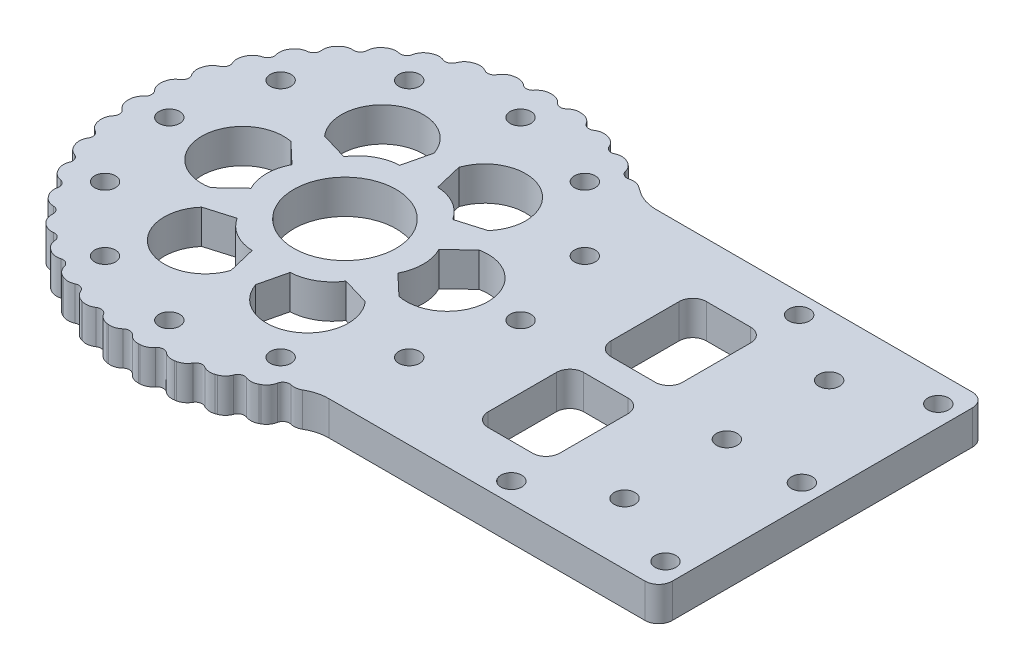
from build123d import *

# Parameters (mm, degrees)
EXTRUDE_1_DEPTH          = 5
FILLET_2_R               = 40
SKETCH_5_R               = 22.5
CUT_EXTRUDE_3_DEPTH      = 6
SKETCH_6_R               = 1.525
CUT_EXTRUDE_4_DEPTH      = 6
SKETCH_8_R               = 18.5
CUT_EXTRUDE_6_DEPTH      = 6
SKETCH_9_R               = 1.275
CUT_EXTRUDE_7_DEPTH      = 6
SKETCH_11_R              = 42.5
EXTRUDE_2_DEPTH          = 5
FILLET_4_R               = 20
SKETCH_13_R              = 31
CUT_EXTRUDE_10_DEPTH     = 5
SKETCH_14_R              = 37.5
EXTRUDE_3_DEPTH          = 5
SKETCH_15_R              = 28.5
CUT_EXTRUDE_11_DEPTH     = 5
SKETCH_16_R              = 2.025
CUT_EXTRUDE_12_DEPTH     = 5
FILLET_5_R               = 20
SKETCH_17_R              = 31
EXTRUDE_4_DEPTH          = 5
CUT_EXTRUDE_13_DEPTH     = 10
PATTERN_CIRCULAR_1_COUNT = 6
SKETCH_19_R              = 7.5
CUT_EXTRUDE_14_DEPTH     = 10
SKETCH_20_W              = 205.824905301
SKETCH_20_H              = 126.942256866
CUT_EXTRUDE_15_DEPTH     = 6.0000001
CUT_EXTRUDE_16_DEPTH     = 6.0000001
SKETCH_23_R              = 1.525
CUT_EXTRUDE_17_DEPTH     = 6
SKETCH_26_R              = 1.525
CUT_EXTRUDE_18_DEPTH     = 6
SKETCH_27_W              = 10.5
SKETCH_27_H              = 14
CUT_EXTRUDE_19_DEPTH     = 6
FILLET_6_R               = 2
FILLET_8_R               = 2
FILLET_10_R              = 2
FILLET_11_R              = 6
SKETCH_28_R              = 1
CUT_EXTRUDE_20_DEPTH     = 6
PATTERN_CIRCULAR_2_COUNT = 40
FILLET_12_R              = 2
SKETCH_29_R              = 1.525
CUT_EXTRUDE_21_DEPTH     = 6.0000001
SKETCH_30_R              = 1.525
CUT_EXTRUDE_22_DEPTH     = 6.0000001


with BuildPart() as part:
    # 草图1 → 凸台-拉伸1 (new body)
    with BuildSketch(Plane(origin=(0, 0, 0), x_dir=(1, 0, 0), z_dir=(0, 1, 0))):
        with BuildLine():
            Line((105, 24), (-76.839744319, 24))
            ThreePointArc((-76.839744319, 24), (-142, 0), (-76.839744319, -24))
            Line((-76.839744319, -24), (105, -24))
            ThreePointArc((105, -24), (129, 0), (105, 24))
        make_face()
    extrude(amount=EXTRUDE_1_DEPTH)

    # 圆角2
    fillet_2_edges = [part.edges().sort_by_distance(p)[0] for p in [
        (-76.839744319, 2.5, -24),
        (-76.839744319, 2.5, 24),
    ]]
    fillet(fillet_2_edges, radius=FILLET_2_R)

    # 草图5 → 切除-拉伸3 (cut, through all)
    with BuildSketch(Plane(origin=(0, 5, 0), x_dir=(1, 0, 0), z_dir=(0, 1, 0))):
        with Locations((-105, 0)):
            Circle(SKETCH_5_R)
    extrude(amount=-CUT_EXTRUDE_3_DEPTH, mode=Mode.SUBTRACT)

    # 草图6 → 切除-拉伸4 (cut, through all)
    with BuildSketch(Plane(origin=(0, 5, 0), x_dir=(1, 0, 0), z_dir=(0, 1, 0))):
        with Locations((-135, 0)):
            Circle(SKETCH_6_R)
        with Locations((-120, 25.980762114)):
            Circle(SKETCH_6_R)
        with Locations((-90, 25.980762114)):
            Circle(SKETCH_6_R)
        with Locations((-75, 0)):
            Circle(SKETCH_6_R)
        with Locations((-90, -25.980762114)):
            Circle(SKETCH_6_R)
        with Locations((-120, -25.980762114)):
            Circle(SKETCH_6_R)
    extrude(amount=-CUT_EXTRUDE_4_DEPTH, mode=Mode.SUBTRACT)

    # 草图8 → 切除-拉伸6 (cut, through all)
    with BuildSketch(Plane(origin=(0, 5, 0), x_dir=(1, 0, 0), z_dir=(0, 1, 0))):
        with Locations((105, 0)):
            Circle(SKETCH_8_R)
    extrude(amount=-CUT_EXTRUDE_6_DEPTH, mode=Mode.SUBTRACT)

    # 草图9 → 切除-拉伸7 (cut, through all)
    with BuildSketch(Plane(origin=(0, 5, 0), x_dir=(1, 0, 0), z_dir=(0, 1, 0))):
        with Locations((130, 0)):
            Circle(SKETCH_9_R)
        with Locations((117.5, -21.650635095)):
            Circle(SKETCH_9_R)
        with Locations((92.5, -21.650635095)):
            Circle(SKETCH_9_R)
        with Locations((80, 0)):
            Circle(SKETCH_9_R)
        with Locations((92.5, 21.650635095)):
            Circle(SKETCH_9_R)
        with Locations((117.5, 21.650635095)):
            Circle(SKETCH_9_R)
    extrude(amount=-CUT_EXTRUDE_7_DEPTH, mode=Mode.SUBTRACT)

    # 草图11 → 凸台-拉伸2 (add)
    with BuildSketch(Plane(origin=(0, 5, 0), x_dir=(1, 0, 0), z_dir=(0, 1, 0))):
        with Locations((-105.000156976, -0.000208065)):
            Circle(SKETCH_11_R)
    extrude(amount=-EXTRUDE_2_DEPTH)

    # 圆角4
    fillet_4_edges = [part.edges().sort_by_distance(p)[0] for p in [
        (-70.546104762, 2.5, 24.883300437),
        (-70.546460155, 2.5, -24.88337639),
    ]]
    fillet(fillet_4_edges, radius=FILLET_4_R)

    # 草图13 → 切除-拉伸10 (cut)
    with BuildSketch(Plane(origin=(0, 5, 0), x_dir=(1, 0, 0), z_dir=(0, 1, 0))):
        with Locations((-105.000156976, -0.000208065)):
            Circle(SKETCH_13_R)
    extrude(amount=-CUT_EXTRUDE_10_DEPTH, mode=Mode.SUBTRACT)

    # 草图14 → 凸台-拉伸3 (add)
    with BuildSketch(Plane(origin=(0, 5, 0), x_dir=(1, 0, 0), z_dir=(0, 1, 0))):
        with Locations((104.999843024, -0.000208065)):
            Circle(SKETCH_14_R)
    extrude(amount=-EXTRUDE_3_DEPTH)

    # 草图15 → 切除-拉伸11 (cut)
    with BuildSketch(Plane(origin=(0, 5, 0), x_dir=(1, 0, 0), z_dir=(0, 1, 0))):
        with Locations((104.999843024, -0.000208065)):
            Circle(SKETCH_15_R)
    extrude(amount=-CUT_EXTRUDE_11_DEPTH, mode=Mode.SUBTRACT)

    # 草图16 → 切除-拉伸12 (cut)
    with BuildSketch(Plane(origin=(0, 5, 0), x_dir=(1, 0, 0), z_dir=(0, 1, 0))):
        with Locations((137.999843024, -0.000208065)):
            Circle(SKETCH_16_R)
        with Locations((121.499843024, -28.57904639)):
            Circle(SKETCH_16_R)
        with Locations((88.499843024, -28.57904639)):
            Circle(SKETCH_16_R)
        with Locations((71.999843024, -0.000208065)):
            Circle(SKETCH_16_R)
        with Locations((88.499843024, 28.57863026)):
            Circle(SKETCH_16_R)
        with Locations((121.499843024, 28.57863026)):
            Circle(SKETCH_16_R)
    extrude(amount=-CUT_EXTRUDE_12_DEPTH, mode=Mode.SUBTRACT)

    # 圆角5
    fillet_5_edges = [part.edges().sort_by_distance(p)[0] for p in [
        (76.185610654, 2.5, 24),
        (76.18595726, 2.5, -24),
    ]]
    fillet(fillet_5_edges, radius=FILLET_5_R)

    # 草图17 → 凸台-拉伸4 (add)
    with BuildSketch(Plane(origin=(0, 5, 0), x_dir=(1, 0, 0), z_dir=(0, 1, 0))):
        with Locations((-105.000156976, -0.000208065)):
            Circle(SKETCH_17_R)
    extrude(amount=-EXTRUDE_4_DEPTH)

    # 草图18 → 切除-拉伸13 (cut)
    with BuildSketch(Plane(origin=(0, 5, 0), x_dir=(1, 0, 0), z_dir=(0, 1, 0))):
        with BuildLine():
            Line((-103.191325759, 14.890330273), (-102.215092539, 10.823665043))
            ThreePointArc((-102.215092539, 10.823665043), (-99.250156976, 9.959084078), (-97.018940116, 7.823665043))
            Line((-97.018940116, 7.823665043), (-93.008988108, 9.011554889))
            ThreePointArc((-93.008988108, 9.011554889), (-94.500156936, 18.186325483), (-103.191325759, 14.890330273))
        make_face()
    cut_extrude_13 = extrude(amount=-CUT_EXTRUDE_13_DEPTH, mode=Mode.SUBTRACT)

    # 阵列(圆周)1: 切除-拉伸13 ×6 about axis
    pattern_circular_1_axis = Axis((-105.000156976, 0, 0.000208065), (0, 1, 0))
    for i in range(1, PATTERN_CIRCULAR_1_COUNT):
        add(cut_extrude_13.rotate(pattern_circular_1_axis, i * 360 / PATTERN_CIRCULAR_1_COUNT), mode=Mode.SUBTRACT)

    # 草图19 → 切除-拉伸14 (cut)
    with BuildSketch(Plane(origin=(0, 5, 0), x_dir=(1, 0, 0), z_dir=(0, 1, 0))):
        with Locations((-105.000156976, -0.000208065)):
            Circle(SKETCH_19_R)
    extrude(amount=-CUT_EXTRUDE_14_DEPTH, mode=Mode.SUBTRACT)

    # 草图20 → 切除-拉伸15 (cut, through all)
    with BuildSketch(Plane(origin=(0, 5, 0), x_dir=(1, 0, 0), z_dir=(0, 1, 0))):
        with Locations((67.912295675, 0)):
            Rectangle(SKETCH_20_W, SKETCH_20_H)
    extrude(amount=-CUT_EXTRUDE_15_DEPTH, mode=Mode.SUBTRACT)

    # 草图21 → 切除-拉伸16 (cut, through all)
    with BuildSketch(Plane(origin=(0, 5, 0), x_dir=(1, 0, 0), z_dir=(0, 1, 0))):
        with BuildLine():
            Line((-85.378994604, 24), (-60.612864986, 24))
            ThreePointArc((-60.612864986, 24), (-68.306975343, 25.539212752), (-74.816798423, 29.919933419))
            ThreePointArc((-74.816798423, 29.919933419), (-147.500156976, -0.000407283), (-74.816517924, -29.920066581))
            ThreePointArc((-74.816517924, -29.920066581), (-68.30664938, -25.539248818), (-60.612452488, -24))
            Line((-60.612452488, -24), (-85.378485613, -24))
            ThreePointArc((-85.378485613, -24), (-136.000156974, -0.000536789), (-85.378994604, 24))
        make_face()
    extrude(amount=-CUT_EXTRUDE_16_DEPTH, mode=Mode.SUBTRACT)

    # 草图23 → 切除-拉伸17 (cut, through all)
    with BuildSketch(Plane(origin=(0, 5, 0), x_dir=(1, 0, 0), z_dir=(0, 1, 0))):
        with Locations((-38.000156976, 0)):
            Circle(SKETCH_23_R)
        with Locations((-38.000156976, 20)):
            Circle(SKETCH_23_R)
        with Locations((-38.000156976, -20)):
            Circle(SKETCH_23_R)
    extrude(amount=-CUT_EXTRUDE_17_DEPTH, mode=Mode.SUBTRACT)

    # 草图26 → 切除-拉伸18 (cut, through all)
    with BuildSketch(Plane(origin=(0, 5, 0), x_dir=(1, 0, 0), z_dir=(0, 1, 0))):
        with Locations((-130.750156976, -0.000208065)):
            Circle(SKETCH_26_R)
        with Locations((-127.300311124, 12.874791935)):
            Circle(SKETCH_26_R)
        with Locations((-117.875156976, 22.299946082)):
            Circle(SKETCH_26_R)
        with Locations((-105.000156976, 25.749791935)):
            Circle(SKETCH_26_R)
        with Locations((-92.125156976, 22.299946082)):
            Circle(SKETCH_26_R)
        with Locations((-82.700002829, 12.874791935)):
            Circle(SKETCH_26_R)
        with Locations((-79.250156976, -0.000208065)):
            Circle(SKETCH_26_R)
        with Locations((-82.700002829, -12.875208065)):
            Circle(SKETCH_26_R)
        with Locations((-92.125156976, -22.300362213)):
            Circle(SKETCH_26_R)
        with Locations((-105.000156976, -25.750208065)):
            Circle(SKETCH_26_R)
        with Locations((-117.875156976, -22.300362213)):
            Circle(SKETCH_26_R)
        with Locations((-127.300311124, -12.875208065)):
            Circle(SKETCH_26_R)
    extrude(amount=-CUT_EXTRUDE_18_DEPTH, mode=Mode.SUBTRACT)

    # 草图27 → 切除-拉伸19 (cut, through all)
    with BuildSketch(Plane(origin=(0, 5, 0), x_dir=(1, 0, 0), z_dir=(0, 1, 0))):
        with Locations((-64.750156976, -9)):
            Rectangle(SKETCH_27_W, SKETCH_27_H)
        with Locations((-64.750156976, 9)):
            Rectangle(SKETCH_27_W, SKETCH_27_H)
    extrude(amount=-CUT_EXTRUDE_19_DEPTH, mode=Mode.SUBTRACT)

    # 圆角6
    fillet_6_edges = [part.edges().sort_by_distance(p)[0] for p in [
        (-59.500156976, 2.5, -16),
        (-59.500156976, 2.5, -2),
        (-70.000156976, 2.5, -2),
        (-70.000156976, 2.5, -16),
    ]]
    fillet(fillet_6_edges, radius=FILLET_6_R)

    # 圆角8
    fillet_8_edges = [part.edges().sort_by_distance(p)[0] for p in [
        (-59.500156976, 2.5, 2),
        (-59.500156976, 2.5, 16),
        (-70.000156976, 2.5, 16),
        (-70.000156976, 2.5, 2),
    ]]
    fillet(fillet_8_edges, radius=FILLET_8_R)

    # 圆角10
    fillet_10_edges = [part.edges().sort_by_distance(p)[0] for p in [
        (-35.000156976, 2.5, -24),
        (-35.000156976, 2.5, 24),
    ]]
    fillet(fillet_10_edges, radius=FILLET_10_R)

    # 圆角11
    fillet_11_edges = [part.edges().sort_by_distance(p)[0] for p in [
        (-85.378994604, 2.5, -24),
        (-85.378485613, 2.5, 24),
    ]]
    fillet(fillet_11_edges, radius=FILLET_11_R)

    # 草图28 → 切除-拉伸20 (cut, through all)
    with BuildSketch(Plane(origin=(0, 5, 0), x_dir=(1, 0, 0), z_dir=(0, 1, 0))):
        with Locations((-113.023547374, 29.94349255)):
            Circle(SKETCH_28_R)
    cut_extrude_20 = extrude(amount=-CUT_EXTRUDE_20_DEPTH, mode=Mode.SUBTRACT)

    # 阵列(圆周)2: 切除-拉伸20 ×40 about axis, 12 skipped
    pattern_circular_2_axis = Axis((-105.000156976, 0, 0.000208065), (0, 1, 0))
    add([cut_extrude_20.rotate(pattern_circular_2_axis, i * 360 / PATTERN_CIRCULAR_2_COUNT) for i in range(1, PATTERN_CIRCULAR_2_COUNT) if i not in (23, 24, 25, 26, 27, 28, 29, 30, 31, 32, 33, 34)], mode=Mode.SUBTRACT)

    # 圆角12
    fillet_12_edges = [part.edges().sort_by_distance(p)[0] for p in [
        (-135.709780191, 2.5, 4.23329701),
        (-135.918809923, 2.5, 2.244511957),
        (-135.993894774, 2.5, -0.622862818),
        (-135.889236477, 2.5, -2.619862082),
        (-135.51484067, 2.5, -5.463680574),
        (-135.099071379, 2.5, -7.419721298),
        (-134.284413781, 2.5, -10.169959257),
        (-133.567771116, 2.5, -12.036877228),
        (-132.332911301, 2.5, -14.625814669),
        (-131.333041382, 2.5, -16.357640169),
        (-129.708385697, 2.5, -18.721528859),
        (-128.449908641, 2.5, -20.275618598),
        (-126.4754615, 2.5, -22.356251753),
        (-124.989365188, 2.5, -23.694338883),
        (-122.713744034, 2.5, -25.440484409),
        (-121.036621088, 2.5, -26.529620784),
        (-118.515859266, 2.5, -27.898282783),
        (-116.689006021, 2.5, -28.711650252),
        (-86.855357582, 2.5, 25.135168875),
        (-112.053572696, 2.5, -30.186698478),
        (-113.985173051, 2.5, -29.669127723),
        (-107.244460868, 2.5, -30.918444881),
        (-109.233245921, 2.5, -30.709415149),
        (-102.380086829, 2.5, -30.888871436),
        (-104.377086093, 2.5, -30.993529732),
        (-97.580227613, 2.5, -30.098706338),
        (-99.536268337, 2.5, -30.514475629),
        (-92.963071683, 2.5, -28.567406075),
        (-94.829989654, 2.5, -29.28404874),
        (-88.642308742, 2.5, -26.332676341),
        (-90.374134242, 2.5, -27.33254626),
        (-105.62322786, 2.5, 30.993945863),
        (-107.620227123, 2.5, 30.889287566),
        (-100.767068031, 2.5, 30.70983128),
        (-102.755853084, 2.5, 30.918861012),
        (-96.015140901, 2.5, 29.669543854),
        (-97.946741256, 2.5, 30.187114609),
        (-91.484454687, 2.5, 27.898698914),
        (-93.311307932, 2.5, 28.712066382),
        (-87.286569919, 2.5, 25.440900539),
        (-88.963692864, 2.5, 26.530036915),
        (-110.464045615, 2.5, 30.514891759),
        (-112.420086339, 2.5, 30.099122468),
        (-115.170324299, 2.5, 29.28446487),
        (-117.037242269, 2.5, 28.567822205),
        (-119.62617971, 2.5, 27.33296239),
        (-121.35800521, 2.5, 26.333092472),
        (-123.721893901, 2.5, 24.708436786),
        (-125.275983639, 2.5, 23.44995973),
        (-127.356616794, 2.5, 21.475512589),
        (-128.694703924, 2.5, 19.989416277),
        (-130.44084945, 2.5, 17.713795123),
        (-131.529985825, 2.5, 16.036672178),
        (-132.898647825, 2.5, 13.515910355),
        (-133.712015293, 2.5, 11.68905711),
        (-134.669492765, 2.5, 8.98522414),
        (-135.18706352, 2.5, 7.053623785),
    ]]
    fillet(fillet_12_edges, radius=FILLET_12_R)

    # 草图29 → 切除-拉伸21 (cut, through all)
    with BuildSketch(Plane(origin=(0, 5, 0), x_dir=(1, 0, 0), z_dir=(0, 1, 0))):
        with Locations((-59.500156976, 21.1)):
            Circle(SKETCH_29_R)
        with Locations((-59.500156976, -21.1)):
            Circle(SKETCH_29_R)
    extrude(amount=-CUT_EXTRUDE_21_DEPTH, mode=Mode.SUBTRACT)

    # 草图30 → 切除-拉伸22 (cut, through all)
    with BuildSketch(Plane.XZ):
        with Locations((-49.000156976, 0)):
            Circle(SKETCH_30_R)
        with Locations((-49.000156976, 15)):
            Circle(SKETCH_30_R)
        with Locations((-49.000156976, -15)):
            Circle(SKETCH_30_R)
    extrude(amount=-CUT_EXTRUDE_22_DEPTH, mode=Mode.SUBTRACT)


solid = part.part
